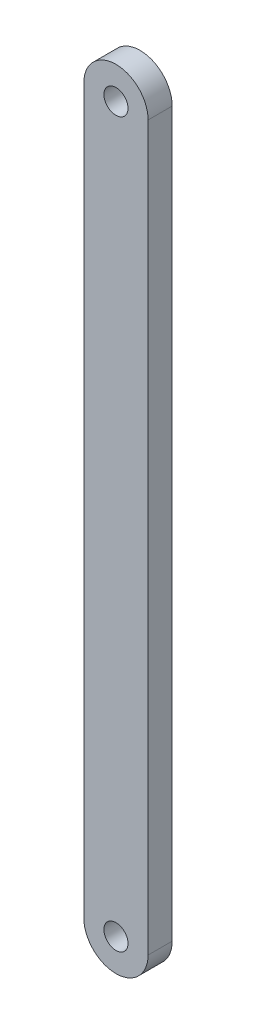
from build123d import *

# Parameters (mm, degrees)
SKETCH_1_W          = 8
SKETCH_1_H          = 90
EXTRUDE_1_DEPTH     = 3
SKETCH_2_R          = 4
EXTRUDE_2_DEPTH     = 3
SKETCH_3_R          = 1.5
CUT_EXTRUDE_1_DEPTH = 3


with BuildPart() as part:
    # 草图1 → 凸台-拉伸1 (new body)
    with BuildSketch(Plane.XY):
        Rectangle(SKETCH_1_W, SKETCH_1_H)
    extrude(amount=EXTRUDE_1_DEPTH)

    # 草图2 → 凸台-拉伸2 (add)
    with BuildSketch(Plane.XY):
        with Locations((0, 45)):
            Circle(SKETCH_2_R)
        with Locations((0, -45)):
            Circle(SKETCH_2_R)
    extrude(amount=EXTRUDE_2_DEPTH)

    # 草图3 → 切除-拉伸1 (cut)
    with BuildSketch(Plane.XY.offset(3)):
        with Locations((0, 45)):
            Circle(SKETCH_3_R)
        with Locations((0, -45)):
            Circle(SKETCH_3_R)
    extrude(amount=-CUT_EXTRUDE_1_DEPTH, mode=Mode.SUBTRACT)


solid = part.part
